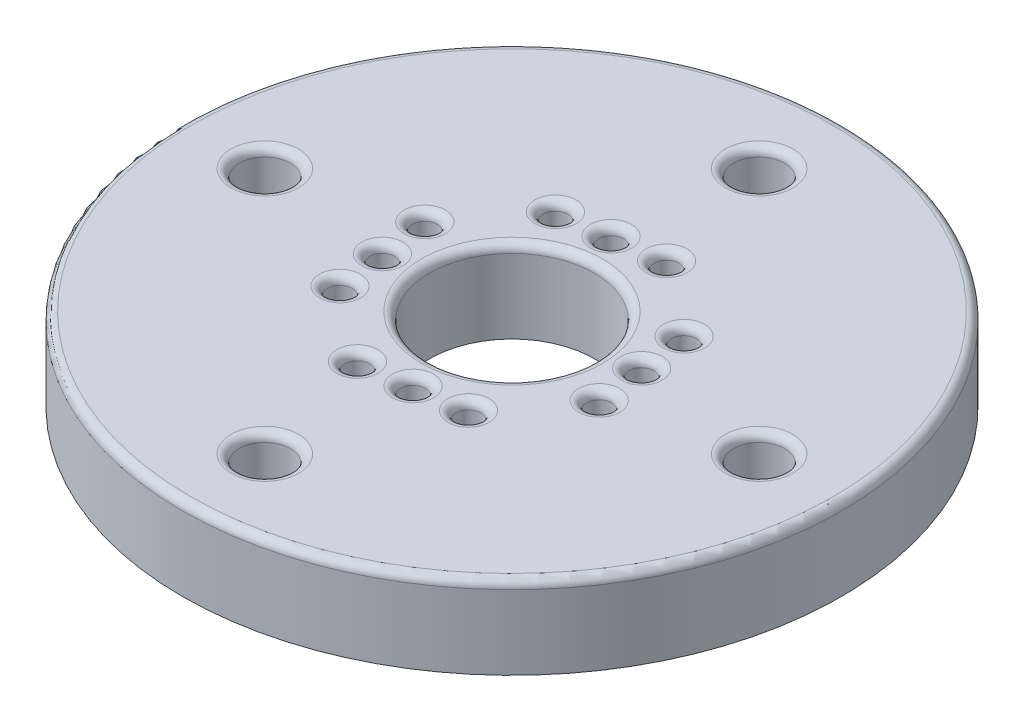
from build123d import *

# Parameters (mm, degrees)
SCHIZZO1_R                    = 20
SCHIZZO1_R_2                  = 1.55
SCHIZZO1_R_3                  = 5
ESTRUSIONE_ESTRUSIONE1_DEPTH  = 5
RACCORDO1_R                   = 0.5
SCHIZZO2_R                    = 0.75
TAGLIO_ESTRUSIONE4_DEPTH      = 1
TAGLIO_ESTRUSIONE4_DEPTH_BACK = 6.0000001
RACCORDO3_R                   = 0.5


with BuildPart() as part:
    # Schizzo1 → Estrusione-Estrusione1 (new body)
    with BuildSketch(Plane(origin=(0, 0, 0), x_dir=(1, 0, 0), z_dir=(0, 1, 0))):
        Circle(SCHIZZO1_R)
        with Locations((0, 15)):
            Circle(SCHIZZO1_R_2, mode=Mode.SUBTRACT)
        with Locations((15, 0)):
            Circle(SCHIZZO1_R_2, mode=Mode.SUBTRACT)
        with Locations((0, -15)):
            Circle(SCHIZZO1_R_2, mode=Mode.SUBTRACT)
        with Locations((-15, 0)):
            Circle(SCHIZZO1_R_2, mode=Mode.SUBTRACT)
        Circle(SCHIZZO1_R_3, mode=Mode.SUBTRACT)
    extrude(amount=ESTRUSIONE_ESTRUSIONE1_DEPTH)

    # Raccordo1
    raccordo1_edges = [part.edges().sort_by_distance(p)[0] for p in [
        (-1.55, 5, 15),
        (-16.55, 5, 0),
        (-5, 5, 0),
        (-20, 5, 0),
        (-1.55, 5, -15),
        (13.45, 5, 0),
    ]]
    fillet(raccordo1_edges, radius=RACCORDO1_R)

    # Schizzo2 → Taglio-Estrusione4 (cut, two sides)
    with BuildSketch(Plane.XZ) as taglio_estrusione4_sk:
        with Locations((-7.336159988, -2.04468986)):
            Circle(SCHIZZO2_R)
        with Locations((-6.938109078, 0.928785459)):
            Circle(SCHIZZO2_R)
        with Locations((-6.540058167, 3.902260778)):
            Circle(SCHIZZO2_R)
        with Locations((-2.04468986, 7.336159988)):
            Circle(SCHIZZO2_R)
        with Locations((0.928785459, 6.938109078)):
            Circle(SCHIZZO2_R)
        with Locations((3.902260778, 6.540058167)):
            Circle(SCHIZZO2_R)
        with Locations((7.336159988, 2.04468986)):
            Circle(SCHIZZO2_R)
        with Locations((6.938109078, -0.928785459)):
            Circle(SCHIZZO2_R)
        with Locations((6.540058167, -3.902260778)):
            Circle(SCHIZZO2_R)
        with Locations((2.04468986, -7.336159988)):
            Circle(SCHIZZO2_R)
        with Locations((-0.928785459, -6.938109078)):
            Circle(SCHIZZO2_R)
        with Locations((-3.902260778, -6.540058167)):
            Circle(SCHIZZO2_R)
    extrude(amount=TAGLIO_ESTRUSIONE4_DEPTH, mode=Mode.SUBTRACT)
    extrude(taglio_estrusione4_sk.sketch, amount=-TAGLIO_ESTRUSIONE4_DEPTH_BACK, mode=Mode.SUBTRACT)

    # Raccordo3
    raccordo3_edges = [part.edges().sort_by_distance(p)[0] for p in [
        (-2.79468986, 5, 7.336159988),
        (0.178785459, 5, 6.938109078),
        (3.152260778, 5, 6.540058167),
        (6.586159988, 5, 2.04468986),
        (6.188109078, 5, -0.928785459),
        (5.790058167, 5, -3.902260778),
        (1.29468986, 5, -7.336159988),
        (-8.086159988, 5, -2.04468986),
        (-4.652260778, 5, -6.540058167),
        (-7.290058167, 5, 3.902260778),
        (-1.678785459, 5, -6.938109078),
        (-7.688109078, 5, 0.928785459),
    ]]
    fillet(raccordo3_edges, radius=RACCORDO3_R)


solid = part.part
